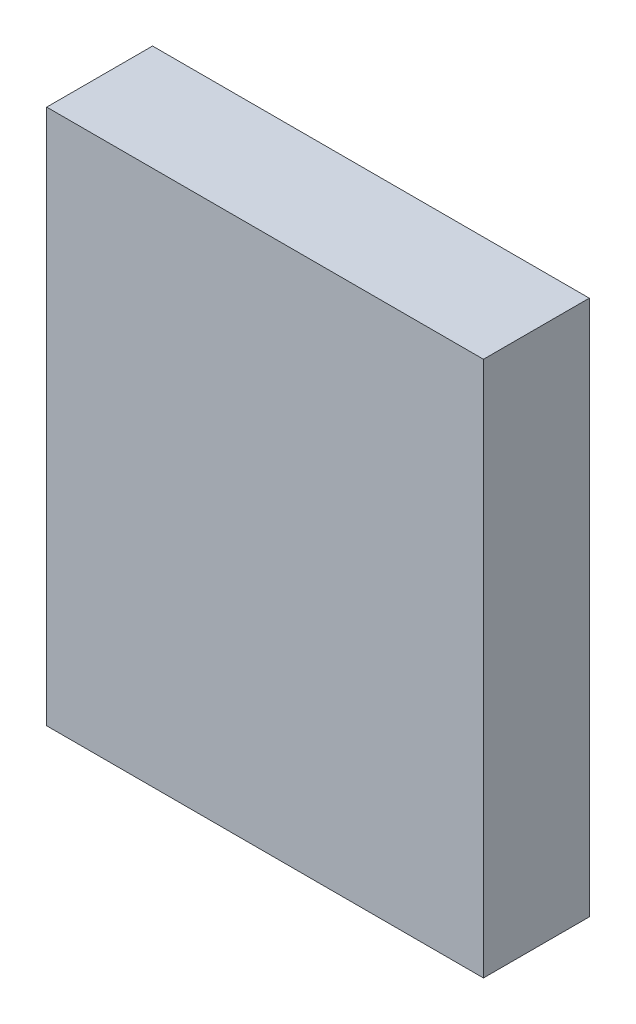
from build123d import *

# Parameters (mm, degrees)
SKETCH1_W               = 4.127
SKETCH1_H               = 5.0635
COMPONENT_OUTLINE_DEPTH = 1


with BuildPart() as part:
    # Sketch1 → Component_Outline (new body)
    with BuildSketch(Plane.XY):
        with Locations((0, 0.03175)):
            Rectangle(SKETCH1_W, SKETCH1_H)
    extrude(amount=COMPONENT_OUTLINE_DEPTH)


solid = part.part
